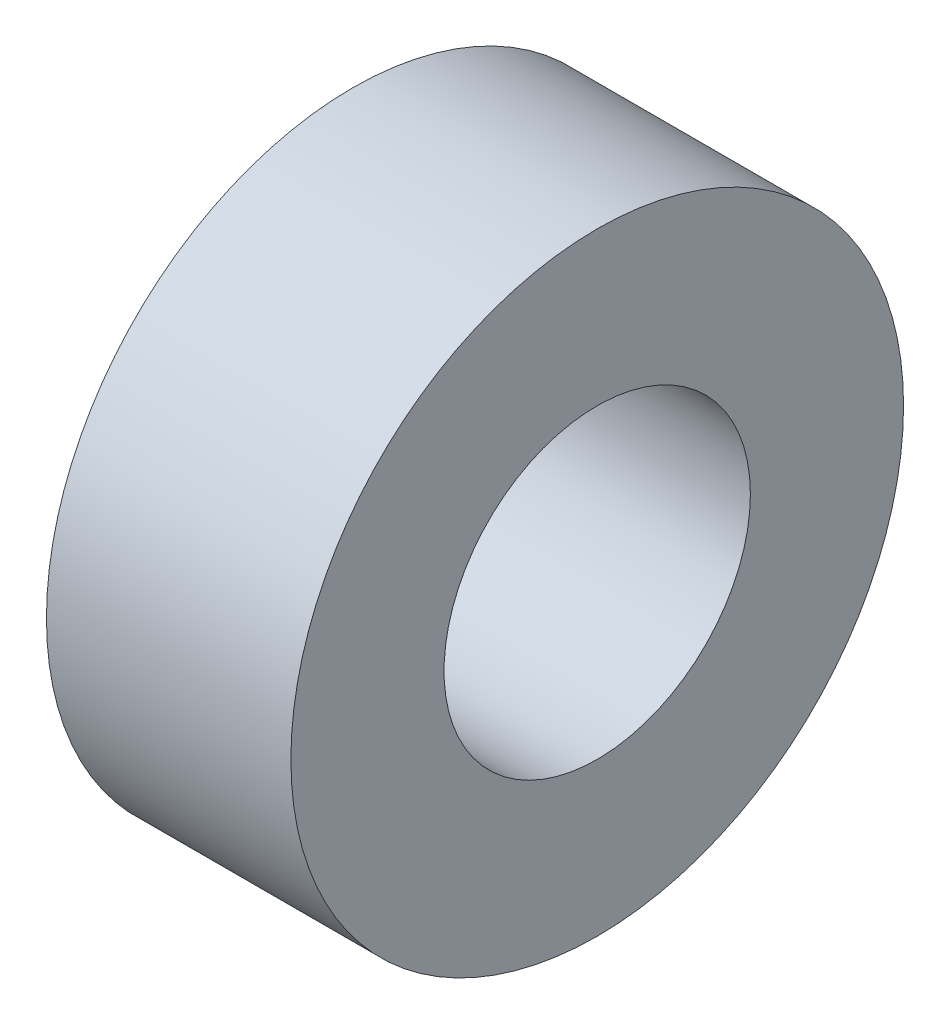
from build123d import *

# Parameters (mm, degrees)
SKETCH1_R           = 9.525
SKETCH1_R_2         = 4.7625
BOSS_EXTRUDE1_DEPTH = 7.60040136


with BuildPart() as part:
    # Sketch1 → Boss-Extrude1 (new body)
    with BuildSketch(Plane(origin=(0, 0, 0), x_dir=(0, 0, -1), z_dir=(1, 0, 0))):
        Circle(SKETCH1_R)
        Circle(SKETCH1_R_2, mode=Mode.SUBTRACT)
    extrude(amount=BOSS_EXTRUDE1_DEPTH)


solid = part.part
